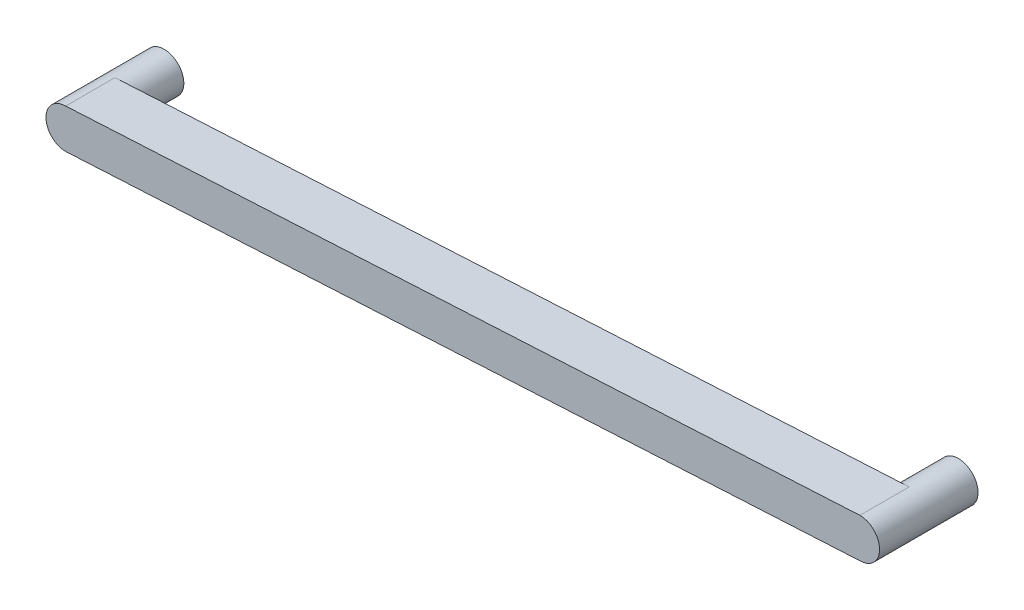
from build123d import *

# Parameters (mm, degrees)
SALIENTE_EXTRUIR1_DEPTH = 1.5
CROQUIS2_R              = 0.6
SALIENTE_EXTRUIR2_DEPTH = 1.5


with BuildPart() as part:
    # Croquis1 → Saliente-Extruir1 (new body)
    with BuildSketch(Plane.XY):
        with BuildLine():
            Line((0, 0.6), (24.2, 1.9))
            ThreePointArc((24.2, 1.9), (24.8, 1.3), (24.2, 0.7))
            Line((24.2, 0.7), (0, -0.6))
            ThreePointArc((0, -0.6), (-0.6, 0), (0, 0.6))
        make_face()
    extrude(amount=SALIENTE_EXTRUIR1_DEPTH)

    # Croquis2 → Saliente-Extruir2 (add)
    with BuildSketch(Plane(origin=(0, 0, 0), x_dir=(-1, 0, 0), z_dir=(0, 0, -1))):
        with Locations((-24.2, 1.3)):
            Circle(CROQUIS2_R)
        Circle(CROQUIS2_R)
    extrude(amount=SALIENTE_EXTRUIR2_DEPTH)


solid = part.part
